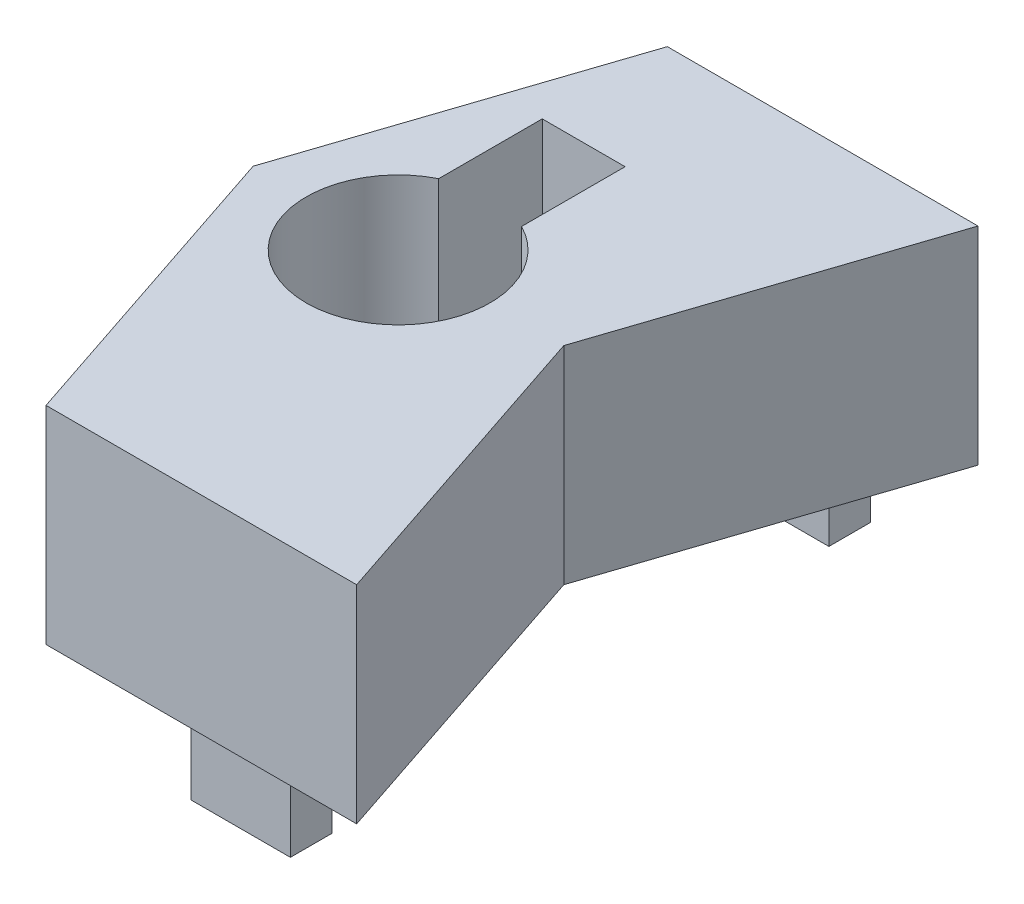
from build123d import *

# Parameters (mm, degrees)
BOSS_EXTRUDE1_DEPTH       = 12.7
SKETCH2_R                 = 5.635000033
HAPTIC_MOTOR_CUTOUT_DEPTH = 9.557999934
SKETCH3_W                 = 5.08
SKETCH3_H                 = 6.35
HAPTIC_WIRE_CUTOUT_DEPTH  = 45.45
SKETCH4_W                 = 6.096
SKETCH4_H                 = 2.54
PINS_DEPTH                = 5.08


with BuildPart() as part:
    # Sketch1 → Boss-Extrude1 (new body)
    with BuildSketch(Plane(origin=(0, 0, 0), x_dir=(1, 0, 0), z_dir=(0, 1, 0))):
        Polygon((0, 0), (19.05, 0), (12.7, 19.05), (19.05, 38.1), (0, 38.1), (-6.35, 19.05), align=None)
    extrude(amount=BOSS_EXTRUDE1_DEPTH)

    # Sketch2 → Haptic Motor Cutout (cut)
    with BuildSketch(Plane.XZ.offset(-12.7)):
        with Locations((2.54, -19.05)):
            Circle(SKETCH2_R)
    extrude(amount=HAPTIC_MOTOR_CUTOUT_DEPTH, mode=Mode.SUBTRACT)

    # Sketch3 → Haptic Wire Cutout (cut, through all)
    with BuildSketch(Plane.XZ):
        with Locations((2.54, -27.255072104)):
            Rectangle(SKETCH3_W, SKETCH3_H)
    extrude(amount=-HAPTIC_WIRE_CUTOUT_DEPTH, mode=Mode.SUBTRACT)

    # Sketch4 → Pins (add)
    with BuildSketch(Plane.XZ):
        with Locations((10.668, -35.56)):
            Rectangle(SKETCH4_W, SKETCH4_H)
    pins = extrude(amount=PINS_DEPTH)

    # Mirror1: Pins across plane
    add(pins.mirror(Plane(origin=(0, 0, -19.05), x_dir=(1, 0, 0), z_dir=(0, 0, -1))))


solid = part.part
